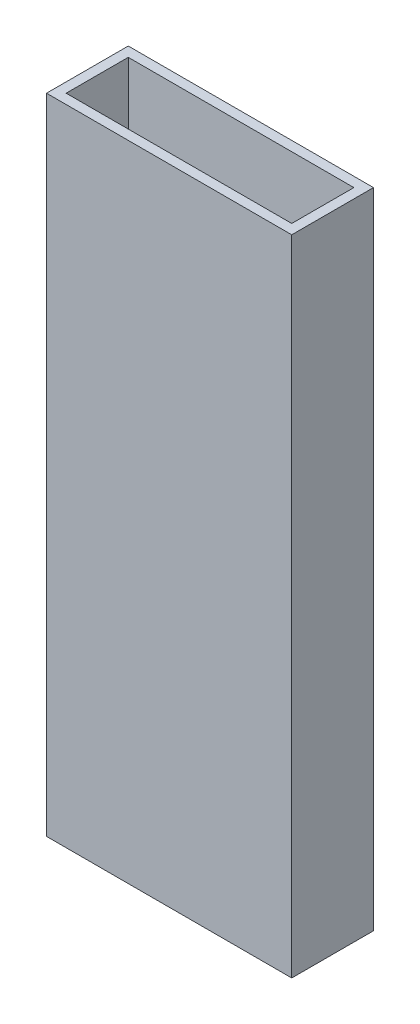
from build123d import *

# Parameters (mm, degrees)
SKETCH1_W           = 76.2
SKETCH1_H           = 25.4
SKETCH1_W_2         = 70.104
SKETCH1_H_2         = 19.304
BOSS_EXTRUDE1_DEPTH = 200


with BuildPart() as part:
    # Sketch1 → Boss-Extrude1 (new body)
    with BuildSketch(Plane(origin=(0, 0, 0), x_dir=(1, 0, 0), z_dir=(0, 1, 0))):
        Rectangle(SKETCH1_W, SKETCH1_H)
        Rectangle(SKETCH1_W_2, SKETCH1_H_2, mode=Mode.SUBTRACT)
    extrude(amount=BOSS_EXTRUDE1_DEPTH)


solid = part.part
